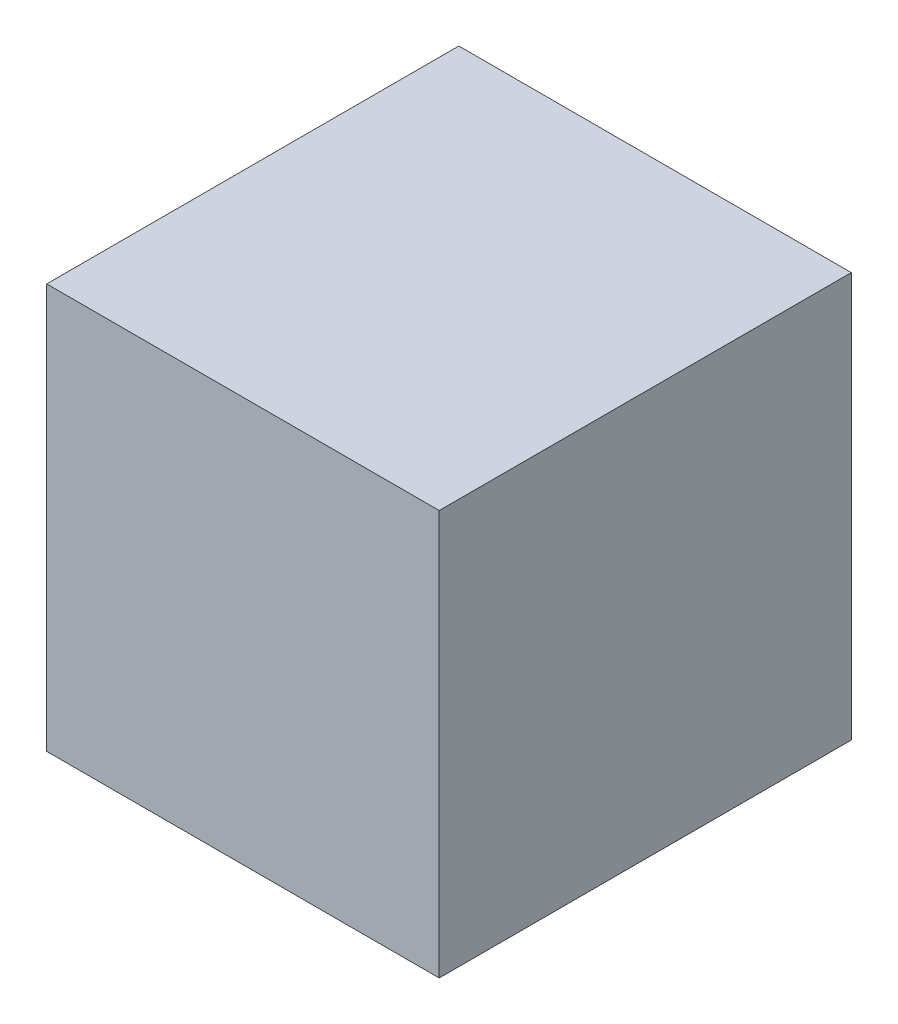
from build123d import *

# Parameters (mm, degrees)
SKETCH1_W           = 38.09940225
SKETCH1_H           = 39.297540676
BOSS_EXTRUDE1_DEPTH = 40
SKETCH1_3_R         = 3.7970867
CUT_EXTRUDE1_DEPTH  = 20


with BuildPart() as part:
    # Sketch1 → Boss-Extrude1 (new body)
    with BuildSketch(Plane.XY):
        with Locations((10.016557459, -10.016557459)):
            Rectangle(SKETCH1_W, SKETCH1_H)
    extrude(amount=BOSS_EXTRUDE1_DEPTH)

    # Sketch1_3 → Cut-Extrude1 (cut)
    with BuildSketch(Plane.XY):
        with Locations((10.016557459, -10.016557459)):
            Circle(SKETCH1_3_R)
    extrude(amount=CUT_EXTRUDE1_DEPTH, mode=Mode.SUBTRACT)


solid = part.part
